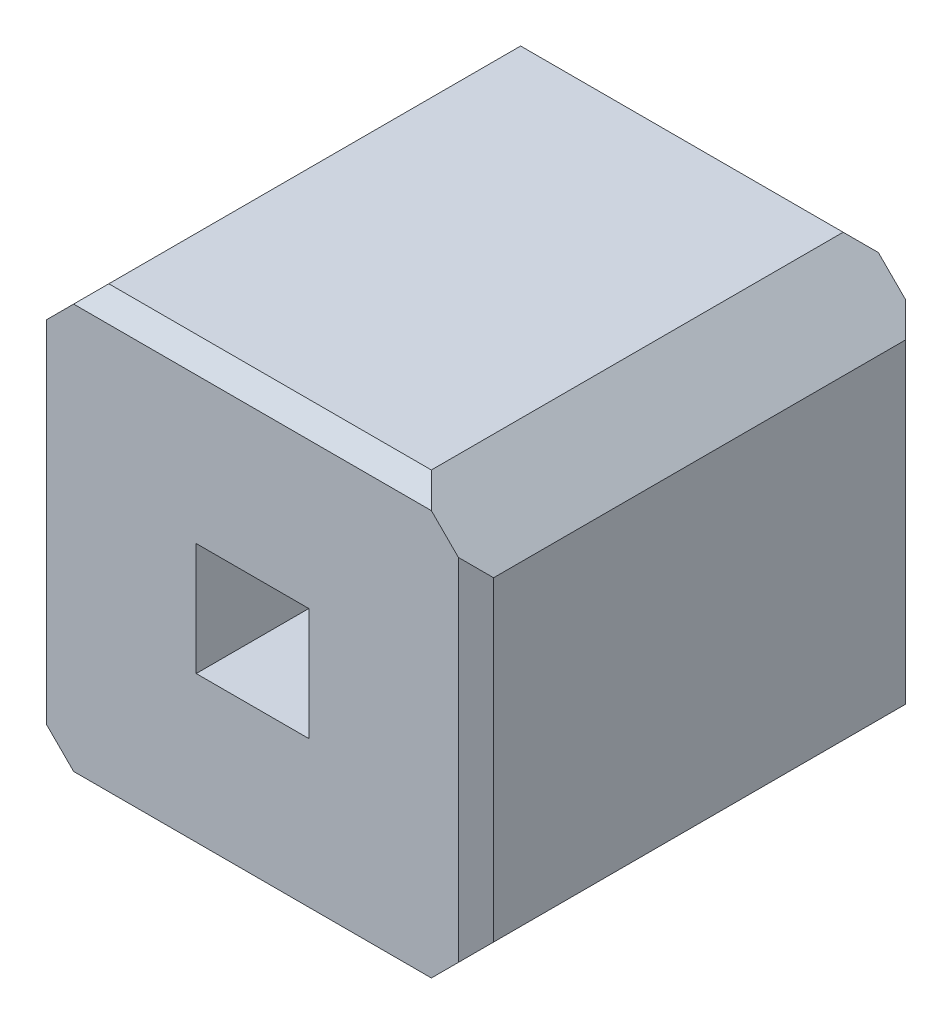
from build123d import *

# Parameters (mm, degrees)
MODEL_W         = 0.64
MODEL_H         = 0.64
EXTRUDE_1_DEPTH = 2.54
CHAMFER_1_SIZE  = 0.1


with BuildPart() as part:
    # Model → Бобышка-Вытянуть1 (new body)
    with BuildSketch(Plane.XY):
        Polygon((-1.27, -0.896446609), (-1.27, 0.896446609), (-1.623553391, 1.25), (-3.456446609, 1.25), (-3.81, 0.896446609), (-3.81, -0.896446609), (-3.456446609, -1.25), (-1.623553391, -1.25), align=None)
        with Locations((-2.54, 0)):
            Rectangle(MODEL_W, MODEL_H, mode=Mode.SUBTRACT)
    extrude(amount=EXTRUDE_1_DEPTH)

    # Фаска1
    chamfer_1_edges = [part.edges().sort_by_distance(p)[0] for p in [
        (-1.27, 0, 0),
        (-2.54, 1.25, 2.54),
        (-3.81, 0, 2.54),
        (-2.54, -1.25, 2.54),
        (-1.27, 0, 2.54),
        (-2.54, -1.25, 0),
        (-3.81, 0, 0),
        (-2.54, 1.25, 0),
    ]]
    chamfer(chamfer_1_edges, length=CHAMFER_1_SIZE)


solid = part.part
